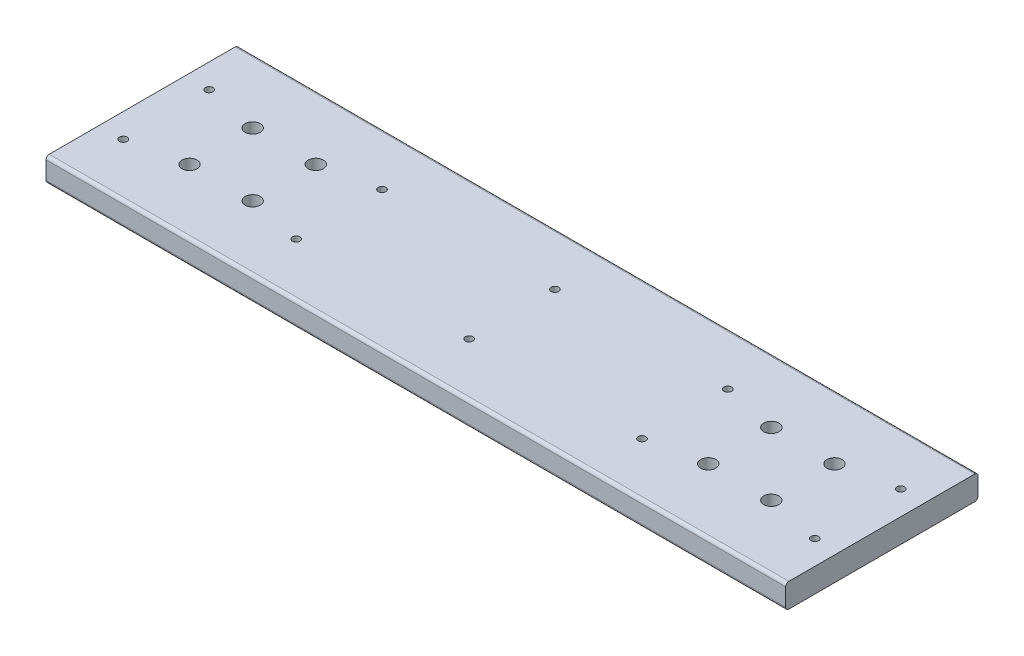
from build123d import *

# Parameters (mm, degrees)
SKETCH1_W             = 76.2
SKETCH1_H             = 9.525
BOSS_EXTRUDE1_DEPTH   = 146.524999939
F_3_0MM_DOWEL_HOLE2_D = 3
FILLET1_R             = 1.27
F_6_0MM_DOWEL_HOLE2_D = 6


with BuildPart() as part:
    # Sketch1 → Boss-Extrude1 (new body, symmetric)
    with BuildSketch(Plane(origin=(0, 0, 0), x_dir=(0, 0, -1), z_dir=(1, 0, 0))):
        with Locations((0, 4.7625)):
            Rectangle(SKETCH1_W, SKETCH1_H)
    extrude(amount=BOSS_EXTRUDE1_DEPTH, both=True)

    # Ø3.0mm Dowel Hole2 (through all)
    with Locations(Plane(origin=(0, 9.525, 0), x_dir=(1, 0, 0), z_dir=(0, 1, 0))):
        with Locations((-137, 17.000000036), (-137, -17.000000036), (-68.5, 17.000000036), (-68.5, -17.000000036), (0, 17.000000036), (0, -17.000000036), (68.5, 17.000000036), (68.5, -17.000000036), (137, 17.000000036), (137, -17.000000036)):
            Hole(F_3_0MM_DOWEL_HOLE2_D / 2)

    # Fillet1
    fillet1_edges = [part.edges().sort_by_distance(p)[0] for p in [
        (0, 9.525, 38.1),
        (0, 9.525, -38.1),
        (0, 0, -38.1),
        (0, 0, 38.1),
    ]]
    fillet(fillet1_edges, radius=FILLET1_R)

    # Ø6.0mm Dowel Hole2 (through all)
    with Locations(Plane(origin=(0, 9.525, 0), x_dir=(1, 0, 0), z_dir=(0, 1, 0))):
        with Locations((-115.25, 12.5), (-115.25, -12.5), (-90.25, 12.5), (-90.25, -12.5), (90.25, 12.5), (90.25, -12.5), (115.25, 12.5), (115.25, -12.5)):
            Hole(F_6_0MM_DOWEL_HOLE2_D / 2)


solid = part.part
